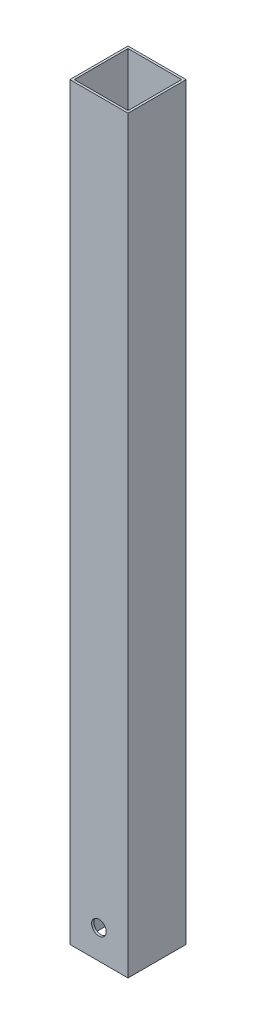
from build123d import *

# Parameters (mm, degrees)
SKETCH1_W           = 25.4
SKETCH1_H           = 25.4
SKETCH1_W_2         = 23.4696
SKETCH1_H_2         = 23.4696
BOSS_EXTRUDE1_DEPTH = 327.152
SKETCH3_R           = 3.175
CUT_EXTRUDE1_DEPTH  = 292.1


with BuildPart() as part:
    # Sketch1 → Boss-Extrude1 (new body)
    with BuildSketch(Plane(origin=(0, 0, 0), x_dir=(1, 0, 0), z_dir=(0, 1, 0))):
        Rectangle(SKETCH1_W, SKETCH1_H)
        Rectangle(SKETCH1_W_2, SKETCH1_H_2, mode=Mode.SUBTRACT)
    extrude(amount=BOSS_EXTRUDE1_DEPTH)

    # Sketch3 → Cut-Extrude1 (cut)
    with BuildSketch(Plane.XY.offset(12.7)):
        with Locations((0, 12.7)):
            Circle(SKETCH3_R)
    extrude(amount=-CUT_EXTRUDE1_DEPTH, mode=Mode.SUBTRACT)


solid = part.part
